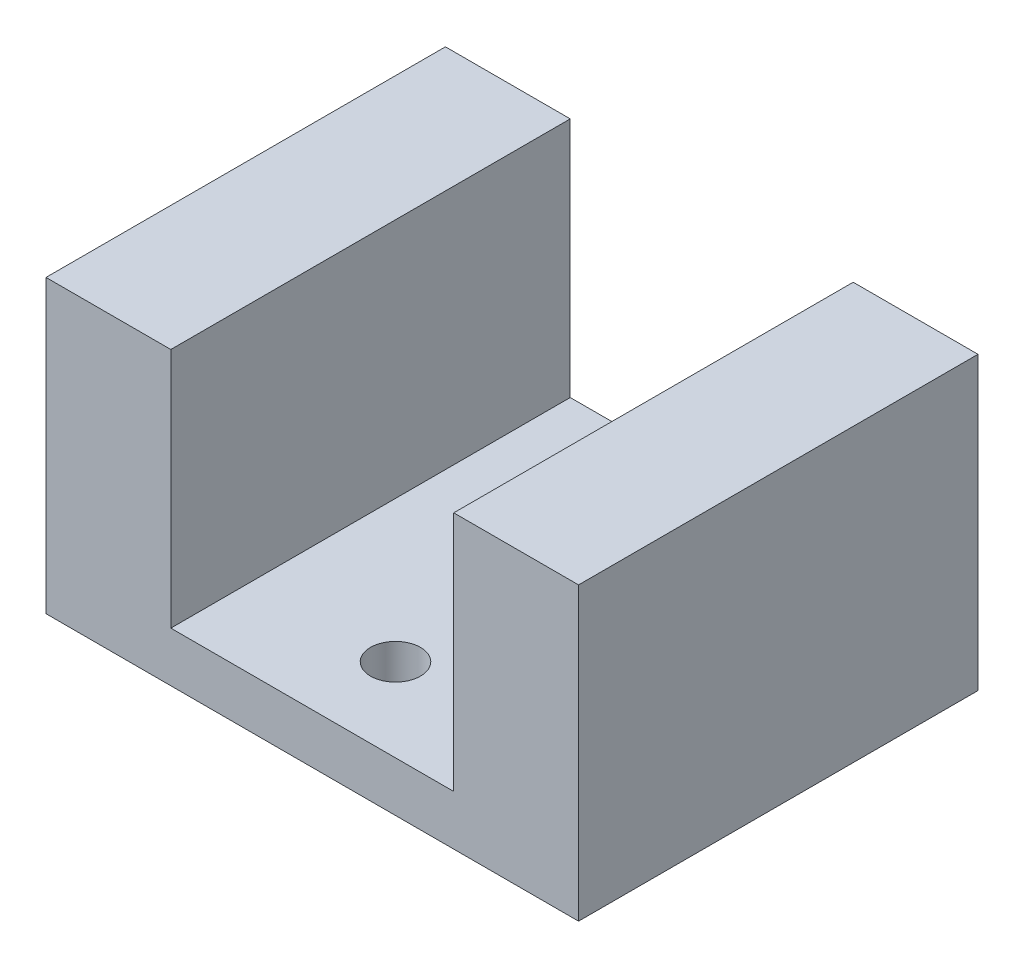
from build123d import *

# Parameters (mm, degrees)
BOSS_EXTRUDE1_DEPTH = 24
CUT_EXTRUDE1_REACH  = 5
SKETCH4_R           = 1.5
SKETCH4_R_2         = 2.05


with BuildPart() as part:
    # Sketch3 → Boss-Extrude1 (new body)
    with BuildSketch(Plane.XY):
        Polygon((-16, 0), (16, 0), (16, 17.5), (8.5, 17.5), (8.5, 3), (-8.5, 3), (-8.5, 17.5), (-16, 17.5), align=None)
    extrude(amount=BOSS_EXTRUDE1_DEPTH)

    # Sketch4 → Cut-Extrude1 (cut, up to next)
    with BuildSketch(Plane(origin=(0, 3, 0), x_dir=(1, 0, 0), z_dir=(0, 1, 0)), mode=Mode.PRIVATE) as cut_extrude1_sk1:
        with Locations((0, -5)):
            Circle(SKETCH4_R)
    cut_extrude1_tool1 = extrude(cut_extrude1_sk1.sketch, amount=-CUT_EXTRUDE1_REACH, mode=Mode.PRIVATE) & part.part
    add(cut_extrude1_tool1.solids().sort_by_distance((0, 3, 5))[0], mode=Mode.SUBTRACT)
    # Sketch4 → Cut-Extrude1 (cut, up to next)
    with BuildSketch(Plane(origin=(0, 3, 0), x_dir=(1, 0, 0), z_dir=(0, 1, 0)), mode=Mode.PRIVATE) as cut_extrude1_sk2:
        with Locations((0, -12)):
            Circle(SKETCH4_R_2)
    cut_extrude1_tool2 = extrude(cut_extrude1_sk2.sketch, amount=-CUT_EXTRUDE1_REACH, mode=Mode.PRIVATE) & part.part
    add(cut_extrude1_tool2.solids().sort_by_distance((0, 3, 12))[0], mode=Mode.SUBTRACT)
    # Sketch4 → Cut-Extrude1 (cut, up to next)
    with BuildSketch(Plane(origin=(0, 3, 0), x_dir=(1, 0, 0), z_dir=(0, 1, 0)), mode=Mode.PRIVATE) as cut_extrude1_sk3:
        with Locations((0, -19)):
            Circle(SKETCH4_R)
    cut_extrude1_tool3 = extrude(cut_extrude1_sk3.sketch, amount=-CUT_EXTRUDE1_REACH, mode=Mode.PRIVATE) & part.part
    add(cut_extrude1_tool3.solids().sort_by_distance((0, 3, 19))[0], mode=Mode.SUBTRACT)


solid = part.part
